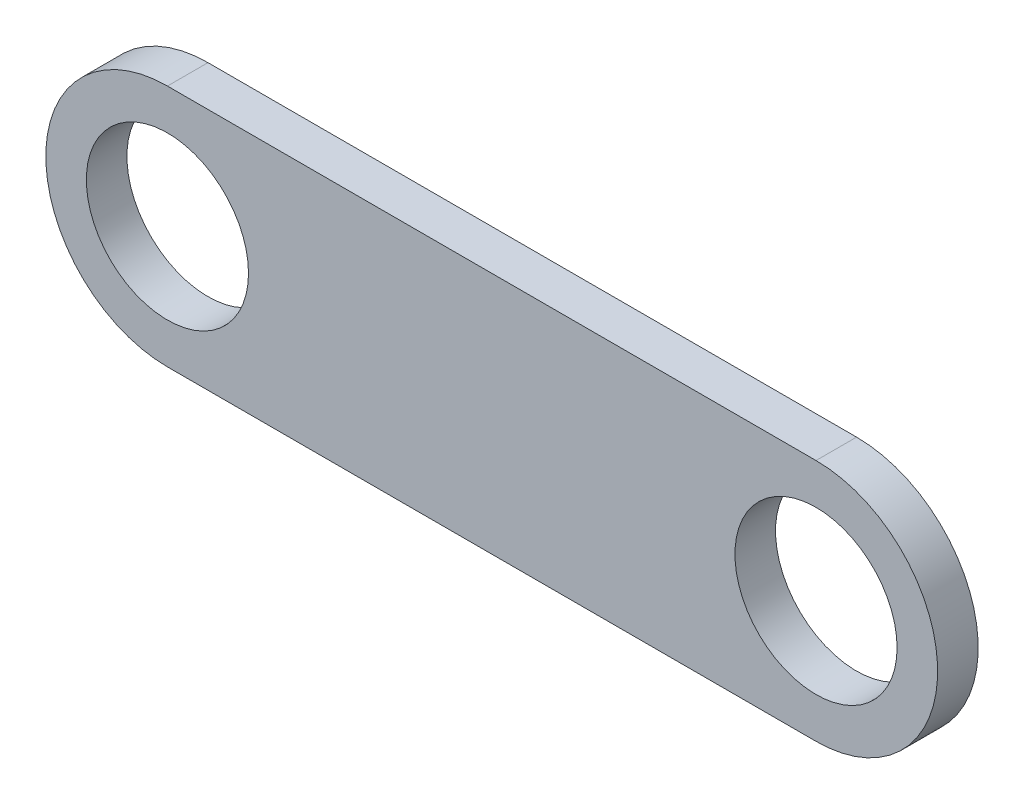
from build123d import *

# Parameters (mm, degrees)
CROQUIS1_R              = 10
SALIENTE_EXTRUIR1_DEPTH = 5


with BuildPart() as part:
    # Croquis1 → Saliente-Extruir1 (new body)
    with BuildSketch(Plane.XY):
        with BuildLine():
            Line((-28.762886598, 11.134020619), (51.237113402, 11.134020619))
            ThreePointArc((51.237113402, 11.134020619), (66.237113402, -3.865979381), (51.237113402, -18.865979381))
            Line((51.237113402, -18.865979381), (-28.762886598, -18.865979381))
            ThreePointArc((-28.762886598, -18.865979381), (-43.762886598, -3.865979381), (-28.762886598, 11.134020619))
        make_face()
        with Locations((-28.762886598, -3.865979381)):
            Circle(CROQUIS1_R, mode=Mode.SUBTRACT)
        with Locations((51.237113402, -3.865979381)):
            Circle(CROQUIS1_R, mode=Mode.SUBTRACT)
    extrude(amount=SALIENTE_EXTRUIR1_DEPTH)


solid = part.part
